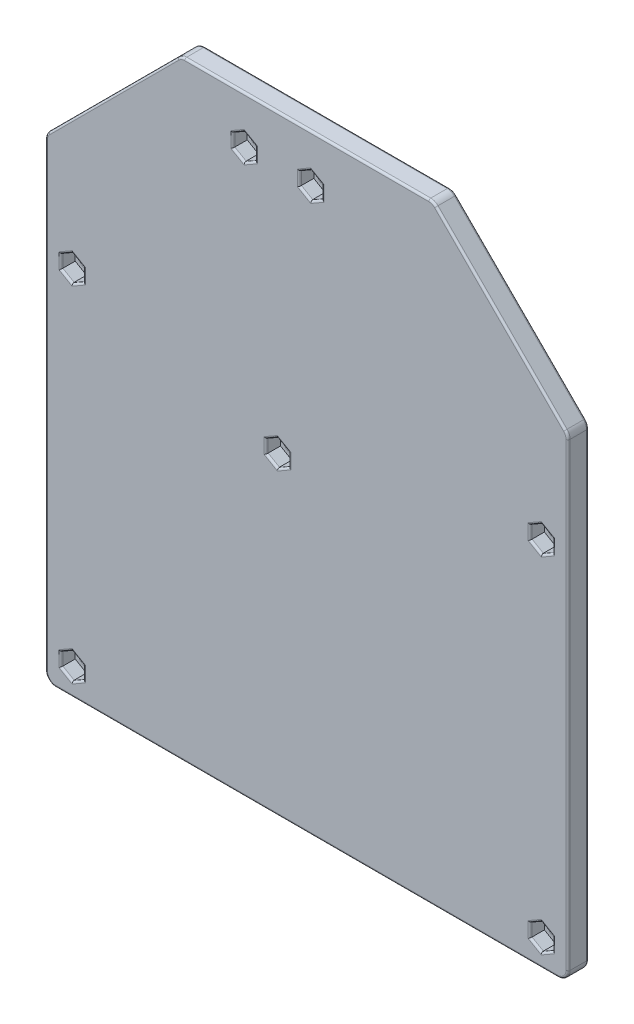
from build123d import *

# Parameters (mm, degrees)
SKETCH1_R           = 1.5
BOSS_EXTRUDE1_DEPTH = 1.5
BOSS_EXTRUDE2_DEPTH = 3.5
FILLET1_R           = 2.5
FILLET2_R           = 0.5


with BuildPart() as part:
    # Sketch1 → Boss-Extrude1 (new body)
    with BuildSketch(Plane.XY):
        Polygon((-56.441952318, -174.575800145), (70.703497827, -174.575800145), (70.703497827, -59.153497827), (37.85, -26.3), (-23.588454491, -26.3), (-56.441952318, -59.153497827), align=None)
        with Locations((-49.941952318, -168.075800145)):
            Circle(SKETCH1_R, mode=Mode.SUBTRACT)
        with Locations((64.203497827, -168.075800145)):
            Circle(SKETCH1_R, mode=Mode.SUBTRACT)
        with Locations((-49.941952318, -84.2574476)):
            Circle(SKETCH1_R, mode=Mode.SUBTRACT)
        with Locations((64.203497827, -84.2574476)):
            Circle(SKETCH1_R, mode=Mode.SUBTRACT)
        with Locations((0, -98.229868737)):
            Circle(SKETCH1_R, mode=Mode.SUBTRACT)
        with Locations((8.1, -37.8)):
            Circle(SKETCH1_R, mode=Mode.SUBTRACT)
        with Locations((-8.1, -37.8)):
            Circle(SKETCH1_R, mode=Mode.SUBTRACT)
    extrude(amount=BOSS_EXTRUDE1_DEPTH)

    # Sketch2 → Boss-Extrude2 (add)
    with BuildSketch(Plane.XY.offset(1.5)):
        Polygon((70.703497827, -59.153497827), (70.703497827, -174.575800145), (-56.441952318, -174.575800145), (-56.441952318, -59.153497827), (-23.588454491, -26.3), (37.85, -26.3), align=None)
        Polygon((8.1, -34.624573519), (5.35, -36.21228676), (5.35, -39.38771324), (8.1, -40.975426481), (10.85, -39.38771324), (10.85, -36.21228676), align=None, mode=Mode.SUBTRACT)
        Polygon((-8.1, -34.624573519), (-10.85, -36.21228676), (-10.85, -39.38771324), (-8.1, -40.975426481), (-5.35, -39.38771324), (-5.35, -36.21228676), align=None, mode=Mode.SUBTRACT)
        Polygon((64.203497827, -81.082021119), (61.453497827, -82.669734359), (61.453497827, -85.84516084), (64.203497827, -87.43287408), (66.953497827, -85.84516084), (66.953497827, -82.669734359), align=None, mode=Mode.SUBTRACT)
        Polygon((0, -95.054442256), (-2.75, -96.642155496), (-2.75, -99.817581977), (0, -101.405295217), (2.75, -99.817581977), (2.75, -96.642155496), align=None, mode=Mode.SUBTRACT)
        Polygon((-49.941952318, -81.082021119), (-52.691952318, -82.669734359), (-52.691952318, -85.84516084), (-49.941952318, -87.43287408), (-47.191952318, -85.84516084), (-47.191952318, -82.669734359), align=None, mode=Mode.SUBTRACT)
        Polygon((-49.941952318, -164.900373665), (-52.691952318, -166.488086905), (-52.691952318, -169.663513386), (-49.941952318, -171.251226626), (-47.191952318, -169.663513386), (-47.191952318, -166.488086905), align=None, mode=Mode.SUBTRACT)
        Polygon((64.203497827, -164.900373665), (61.453497827, -166.488086905), (61.453497827, -169.663513386), (64.203497827, -171.251226626), (66.953497827, -169.663513386), (66.953497827, -166.488086905), align=None, mode=Mode.SUBTRACT)
    extrude(amount=BOSS_EXTRUDE2_DEPTH)

    # Fillet1
    fillet1_edges = [part.edges().sort_by_distance(p)[0] for p in [
        (-56.441952318, -59.153497827, 2.5),
        (-23.588454491, -26.3, 2.5),
        (37.85, -26.3, 2.5),
        (70.703497827, -59.153497827, 2.5),
        (70.703497827, -174.575800145, 2.5),
        (-56.441952318, -174.575800145, 2.5),
    ]]
    fillet(fillet1_edges, radius=FILLET1_R)

    # Fillet2
    fillet2_edges = [part.edges().sort_by_distance(p)[0] for p in [
        (62.828497827, -165.694230285, 5),
        (61.453497827, -168.075800145, 5),
        (62.828497827, -170.457370006, 5),
        (65.578497827, -170.457370006, 5),
        (66.953497827, -168.075800145, 5),
        (-51.441952318, -168.075800145, 0),
        (-51.441952318, -168.075800145, 1.5),
        (7.130772754, -26.3, 0),
        (7.130772754, -26.3, 5),
        (-56.441952318, -116.132415939, 0),
        (-40.015203404, -42.726748913, 0),
        (54.276748913, -42.726748913, 0),
        (70.703497827, -116.132415939, 0),
        (7.130772754, -174.575800145, 0),
        (69.97126478, -173.843567098, 0),
        (70.513196658, -59.232323152, 0),
        (-55.709719271, -173.843567098, 0),
        (-56.251651149, -59.232323152, 0),
        (-23.509629166, -26.490301169, 0),
        (37.771174675, -26.490301169, 0),
        (54.276748913, -42.726748913, 5),
        (-40.015203404, -42.726748913, 5),
        (-56.441952318, -116.132415939, 5),
        (7.130772754, -174.575800145, 5),
        (70.703497827, -116.132415939, 5),
        (69.97126478, -173.843567098, 5),
        (70.513196658, -59.232323152, 5),
        (-55.709719271, -173.843567098, 5),
        (-56.251651149, -59.232323152, 5),
        (-23.509629166, -26.490301169, 5),
        (37.771174675, -26.490301169, 5),
        (62.703497827, -168.075800145, 0),
        (62.703497827, -168.075800145, 1.5),
        (-51.441952318, -84.2574476, 0),
        (-51.441952318, -84.2574476, 1.5),
        (62.703497827, -84.2574476, 0),
        (62.703497827, -84.2574476, 1.5),
        (-1.5, -98.229868737, 0),
        (-1.5, -98.229868737, 1.5),
        (6.6, -37.8, 0),
        (6.6, -37.8, 1.5),
        (-9.6, -37.8, 0),
        (-9.6, -37.8, 1.5),
        (9.475, -35.41843014, 5),
        (6.725, -35.41843014, 5),
        (5.35, -37.8, 5),
        (6.725, -40.18156986, 5),
        (9.475, -40.18156986, 5),
        (10.85, -37.8, 5),
        (-6.725, -35.41843014, 5),
        (-9.475, -35.41843014, 5),
        (-10.85, -37.8, 5),
        (-9.475, -40.18156986, 5),
        (-6.725, -40.18156986, 5),
        (-5.35, -37.8, 5),
        (65.578497827, -81.875877739, 5),
        (62.828497827, -81.875877739, 5),
        (61.453497827, -84.2574476, 5),
        (62.828497827, -86.63901746, 5),
        (65.578497827, -86.63901746, 5),
        (66.953497827, -84.2574476, 5),
        (1.375, -95.848298876, 5),
        (-1.375, -95.848298876, 5),
        (-2.75, -98.229868737, 5),
        (-1.375, -100.611438597, 5),
        (1.375, -100.611438597, 5),
        (2.75, -98.229868737, 5),
        (-48.566952318, -81.875877739, 5),
        (-51.316952318, -81.875877739, 5),
        (-52.691952318, -84.2574476, 5),
        (-51.316952318, -86.63901746, 5),
        (-48.566952318, -86.63901746, 5),
        (-47.191952318, -84.2574476, 5),
        (-48.566952318, -165.694230285, 5),
        (-51.316952318, -165.694230285, 5),
        (-52.691952318, -168.075800145, 5),
        (-51.316952318, -170.457370006, 5),
        (-48.566952318, -170.457370006, 5),
        (-47.191952318, -168.075800145, 5),
        (65.578497827, -165.694230285, 5),
    ]]
    fillet(fillet2_edges, radius=FILLET2_R)


solid = part.part
